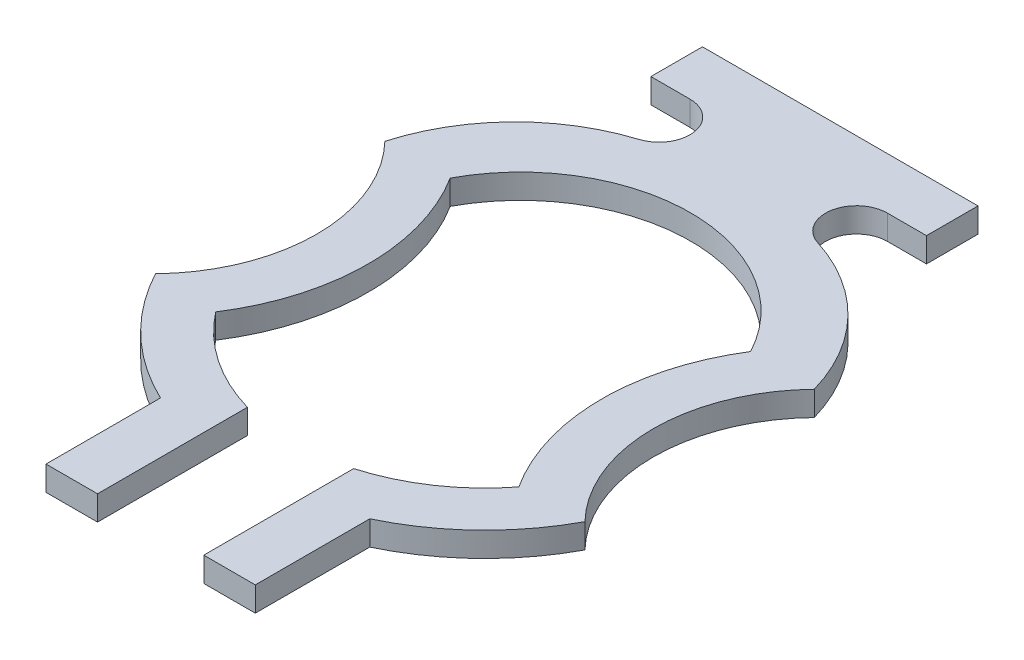
from build123d import *

# Parameters (mm, degrees)
BOSS_EXTRUDE1_DEPTH = 0.075


with BuildPart() as part:
    # Sketch1 → Boss-Extrude1 (new body)
    with BuildSketch(Plane(origin=(0, 0, 0), x_dir=(1, 0, 0), z_dir=(0, 1, 0))):
        with BuildLine():
            Line((-0.4212, 1.0862), (0.4212, 1.0862))
            Line((0.4212, 1.0862), (0.4212, 0.9287))
            Line((0.4212, 0.9287), (0.30186515, 0.9287))
            ThreePointArc((0.30186515, 0.9287), (0.208363685, 0.848474841), (0.273449322, 0.743868627))
            ThreePointArc((0.273449322, 0.743868627), (0.514449909, 0.595458709), (0.656331281, 0.350557785))
            ThreePointArc((0.656331281, 0.350557785), (0.5146, -8.225e-06), (0.656342713, -0.350569612))
            ThreePointArc((0.656342713, -0.350569612), (0.513871298, -0.538164565), (0.3199, -0.671824977))
            Line((0.3199, -0.671824977), (0.3199, -1.0218))
            Line((0.3199, -1.0218), (0.1624, -1.0218))
            Line((0.1624, -1.0218), (0.1624, -0.563567645))
            ThreePointArc((0.1624, -0.563567645), (0.32905661, -0.485493561), (0.463312875, -0.359615669))
            ThreePointArc((0.463312875, -0.359615669), (0.357111084, -0.003830472), (0.459187913, 0.353160072))
            ThreePointArc((0.459187913, 0.353160072), (0, 0.6288), (-0.459187913, 0.353160072))
            ThreePointArc((-0.459187913, 0.353160072), (-0.357111084, -0.003830472), (-0.463312875, -0.359615669))
            ThreePointArc((-0.463312875, -0.359615669), (-0.32905661, -0.485493561), (-0.1624, -0.563567645))
            Line((-0.1624, -0.563567645), (-0.1624, -1.0218))
            Line((-0.1624, -1.0218), (-0.3199, -1.0218))
            Line((-0.3199, -1.0218), (-0.3199, -0.671824977))
            ThreePointArc((-0.3199, -0.671824977), (-0.513871298, -0.538164565), (-0.656342713, -0.350569612))
            ThreePointArc((-0.656342713, -0.350569612), (-0.5146, -8.225e-06), (-0.656331281, 0.350557785))
            ThreePointArc((-0.656331281, 0.350557785), (-0.514449909, 0.595458709), (-0.273449322, 0.743868627))
            ThreePointArc((-0.273449322, 0.743868627), (-0.208363685, 0.848474841), (-0.30186515, 0.9287))
            Line((-0.30186515, 0.9287), (-0.4212, 0.9287))
            Line((-0.4212, 0.9287), (-0.4212, 1.0862))
        make_face()
    extrude(amount=BOSS_EXTRUDE1_DEPTH)


solid = part.part
